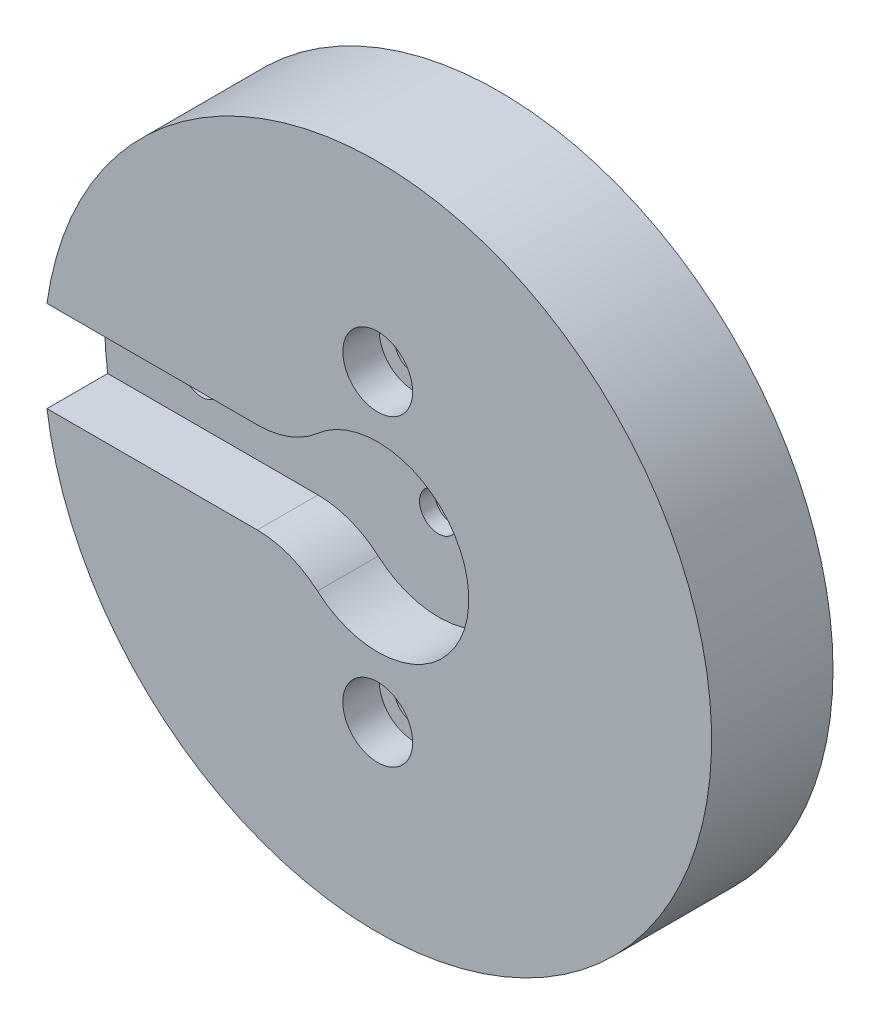
from build123d import *

# Parameters (mm, degrees)
SKETCH3_R                = 7.408333333
BOSS_EXTRUDE1_DEPTH      = 7.62
CUT_EXTRUDE1_START       = -8.62
CUT_EXTRUDE1_DEPTH       = 9.62
FILLET1_R                = 0.355076163
CIRPATTERN1_COUNT        = 12
FILLET1_OF_CIRPATTERN1_R = 0.355076163
SCALE1_SCALE             = 2.5
SKETCH10_R               = 27.94
BOSS_EXTRUDE4_DEPTH      = 10.16
SKETCH11_R               = 5.08
CUT_EXTRUDE5_DEPTH       = 30.21
CUT_EXTRUDE6_DEPTH       = 5.08
SKETCH13_R               = 1.5875
CUT_EXTRUDE12_DEPTH      = 25.1300001
SKETCH16_R               = 2.74955
CUT_EXTRUDE13_DEPTH      = 3.81
SKETCH18_R               = 5.08
BOSS_EXTRUDE5_DEPTH      = 24.13
SKETCH19_R               = 2.794
CUT_EXTRUDE14_DEPTH      = 22.86
SKETCH20_R               = 1.5875
CUT_EXTRUDE15_DEPTH      = 7.62
SKETCH21_R               = 26.202104712
GEAR_CUT_EXTRUDE_DEPTH   = 19.05
SKETCH22_R               = 1.651
CUT_EXTRUDE17_DEPTH      = 10.16
SKETCH23_R               = 2.921
CUT_EXTRUDE18_DEPTH      = 3.048


with BuildPart() as part:
    # Sketch3 → Boss-Extrude1 (new body)
    with BuildSketch(Plane.XY):
        Circle(SKETCH3_R)
    extrude(amount=-BOSS_EXTRUDE1_DEPTH)

    # Sketch4 → Cut-Extrude1 (cut)
    with BuildSketch(Plane.XY.offset(CUT_EXTRUDE1_START)):
        with BuildLine():
            Line((4.993301754, 0.581811335), (5.926950078, 0.690598508))
            add(Edge.make_bspline(
                [(5.926950078, 0.690598508), (5.929318191, 0.690911872), (5.935944647, 0.691904892), (5.948407954, 0.694232443), (5.96863478, 0.69866684), (5.994230847, 0.70524939), (6.027084964, 0.714822349), (6.065467787, 0.727462413), (6.107282331, 0.74277265), (6.152345854, 0.760950457), (6.196898763, 0.780422108), (6.240942495, 0.801081108), (6.284441008, 0.822769247), (6.336662498, 0.8503395), (6.398612769, 0.885198626), (6.469984516, 0.92853373), (6.54965538, 0.980716028), (6.629400976, 1.037091207), (6.706647925, 1.095172788), (6.78320647, 1.156800213), (6.856219389, 1.218511327), (6.930432721, 1.285554849), (6.998115798, 1.348944008), (7.07205666, 1.423150182), (7.131183599, 1.483972917), (7.190627906, 1.549410219), (7.219315962, 1.581641114), (7.233873511, 1.598273068)],
                knots=[0, 0, 0, 0, 0, 0.005376749, 0.015083688, 0.02853182, 0.046610139, 0.064854849, 0.092110525, 0.119476176, 0.146842496, 0.174208854, 0.201574956, 0.228941013, 0.256307345, 0.307035032, 0.361767352, 0.416499661, 0.471231937, 0.525964282, 0.580696615, 0.635428982, 0.690161387, 0.744893688, 0.799626082, 0.854358408, 0.909090915, 0.909090915, 0.909090915, 0.909090915, 0.909090915], degree=4))
            ThreePointArc((7.233873511, 1.598273068), (7.408333333, 0), (7.233873511, -1.598273068))
            add(Edge.make_bspline(
                [(5.926950078, -0.690598508), (5.929318191, -0.690911872), (5.935944647, -0.691904892), (5.948407954, -0.694232443), (5.96863478, -0.69866684), (5.994230847, -0.70524939), (6.027084964, -0.714822349), (6.065467787, -0.727462413), (6.107282331, -0.74277265), (6.152345854, -0.760950457), (6.196898763, -0.780422108), (6.240942495, -0.801081108), (6.284441008, -0.822769247), (6.336662498, -0.8503395), (6.398612769, -0.885198626), (6.469984516, -0.92853373), (6.54965538, -0.980716028), (6.629400976, -1.037091207), (6.706647925, -1.095172788), (6.78320647, -1.156800213), (6.856219389, -1.218511327), (6.930432721, -1.285554849), (6.998115798, -1.348944008), (7.07205666, -1.423150182), (7.131183599, -1.483972917), (7.190627906, -1.549410219), (7.219315962, -1.581641114), (7.233873511, -1.598273068)],
                knots=[0, 0, 0, 0, 0, 0.005376749, 0.015083688, 0.02853182, 0.046610139, 0.064854849, 0.092110525, 0.119476176, 0.146842496, 0.174208854, 0.201574956, 0.228941013, 0.256307345, 0.307035032, 0.361767352, 0.416499661, 0.471231937, 0.525964282, 0.580696615, 0.635428982, 0.690161387, 0.744893688, 0.799626082, 0.854358408, 0.909090915, 0.909090915, 0.909090915, 0.909090915, 0.909090915], degree=4))
            Line((5.926950078, -0.690598508), (4.993301754, -0.581811335))
            ThreePointArc((4.993301754, -0.581811335), (5.027083333, 0), (4.993301754, 0.581811335))
        make_face()
    cut_extrude1 = extrude(amount=CUT_EXTRUDE1_DEPTH, mode=Mode.SUBTRACT)

    # Fillet1
    fillet1_edges = [part.edges().sort_by_distance(p)[0] for p in [
        (4.993301754, -0.581811335, -3.81),
        (4.993301754, 0.581811335, -3.81),
    ]]
    fillet(fillet1_edges, radius=FILLET1_R)

    # CirPattern1: Cut-Extrude1 ×12 about axis
    cirpattern1_axis = Axis((0, 0, 6.35), (0, 0, -1))
    for i in range(1, CIRPATTERN1_COUNT):
        add(cut_extrude1.rotate(cirpattern1_axis, i * 360 / CIRPATTERN1_COUNT), mode=Mode.SUBTRACT)

    # Fillet1 of CirPattern1
    fillet1_of_cirpattern1_edges = [part.edges().sort_by_distance(p)[0] for p in [
        (4.0334205, -3.000514274, -3.81),
        (4.615231836, -1.99278748, -3.81),
        (1.99278748, -4.615231836, -3.81),
        (3.000514274, -4.0334205, -3.81),
        (-0.581811335, -4.993301754, -3.81),
        (0.581811335, -4.993301754, -3.81),
        (-3.000514274, -4.0334205, -3.81),
        (-1.99278748, -4.615231836, -3.81),
        (-4.615231836, -1.99278748, -3.81),
        (-4.0334205, -3.000514274, -3.81),
        (-4.993301754, 0.581811335, -3.81),
        (-4.993301754, -0.581811335, -3.81),
        (-4.0334205, 3.000514274, -3.81),
        (-4.615231836, 1.99278748, -3.81),
        (-1.99278748, 4.615231836, -3.81),
        (-3.000514274, 4.0334205, -3.81),
        (0.581811335, 4.993301754, -3.81),
        (-0.581811335, 4.993301754, -3.81),
        (3.000514274, 4.0334205, -3.81),
        (1.99278748, 4.615231836, -3.81),
        (4.615231836, 1.99278748, -3.81),
        (4.0334205, 3.000514274, -3.81),
    ]]
    fillet(fillet1_of_cirpattern1_edges, radius=FILLET1_OF_CIRPATTERN1_R)


with BuildPart() as part_1:
    # Scale1: scaled about (0, 0, 0)
    add(part.part.scale(SCALE1_SCALE))

    # Sketch10 → Boss-Extrude4 (add)
    with BuildSketch(Plane.XY):
        Circle(SKETCH10_R)
    extrude(amount=BOSS_EXTRUDE4_DEPTH)

    # Sketch11 → Cut-Extrude5 (cut, through all)
    with BuildSketch(Plane(origin=(0, 0, -19.05), x_dir=(-1, 0, 0), z_dir=(0, 0, -1))):
        Circle(SKETCH11_R)
    extrude(amount=-CUT_EXTRUDE5_DEPTH, mode=Mode.SUBTRACT)

    # Sketch12 → Cut-Extrude6 (cut)
    with BuildSketch(Plane.XY.offset(10.16)):
        with BuildLine():
            Line((-10.080312495, -3.81), (-28.438556916, -3.81))
            Line((-28.438556916, -3.81), (-28.438556916, 3.81))
            Line((-28.438556916, 3.81), (-10.080312495, 3.81))
            ThreePointArc((-10.080312495, 3.81), (-7.386235659, 4.302142678), (-5.040156248, 5.715))
            ThreePointArc((-5.040156248, 5.715), (7.62, 0), (-5.040156248, -5.715))
            ThreePointArc((-5.040156248, -5.715), (-7.386235659, -4.302142678), (-10.080312495, -3.81))
        make_face()
    extrude(amount=-CUT_EXTRUDE6_DEPTH, mode=Mode.SUBTRACT)

    # Sketch13 → Cut-Extrude12 (cut, through all)
    with BuildSketch(Plane.XY.offset(5.08)):
        with Locations((-19.812, 0)):
            Circle(SKETCH13_R)
    extrude(amount=-CUT_EXTRUDE12_DEPTH, mode=Mode.SUBTRACT)

    # Sketch16 → Cut-Extrude13 (cut)
    with BuildSketch(Plane(origin=(0, 0, 0), x_dir=(-1, 0, 0), z_dir=(0, 0, -1))):
        with Locations((19.812, 0)):
            Circle(SKETCH16_R)
    extrude(amount=-CUT_EXTRUDE13_DEPTH, mode=Mode.SUBTRACT)

    # Sketch18 → Boss-Extrude5 (add)
    with BuildSketch(Plane(origin=(0, 0, -19.05), x_dir=(-1, 0, 0), z_dir=(0, 0, -1))):
        Circle(SKETCH18_R)
    extrude(amount=-BOSS_EXTRUDE5_DEPTH)

    # Sketch19 → Cut-Extrude14 (cut)
    with BuildSketch(Plane(origin=(0, 0, -19.05), x_dir=(-1, 0, 0), z_dir=(0, 0, -1))):
        Circle(SKETCH19_R)
    extrude(amount=-CUT_EXTRUDE14_DEPTH, mode=Mode.SUBTRACT)

    # Sketch20 → Cut-Extrude15 (cut)
    with BuildSketch(Plane(origin=(0, 0, 3.81), x_dir=(-1, 0, 0), z_dir=(0, 0, -1))):
        Circle(SKETCH20_R)
    extrude(amount=-CUT_EXTRUDE15_DEPTH, mode=Mode.SUBTRACT)

    # Sketch21 → Gear Cut Extrude (cut)
    with BuildSketch(Plane(origin=(0, 0, -19.05), x_dir=(-1, 0, 0), z_dir=(0, 0, -1))):
        Circle(SKETCH21_R)
    extrude(amount=-GEAR_CUT_EXTRUDE_DEPTH, mode=Mode.SUBTRACT)

    # Sketch22 → Cut-Extrude17 (cut)
    with BuildSketch(Plane.XY.offset(10.16)):
        with Locations((0, 12.7)):
            Circle(SKETCH22_R)
        with Locations((0, -12.7)):
            Circle(SKETCH22_R)
    extrude(amount=-CUT_EXTRUDE17_DEPTH, mode=Mode.SUBTRACT)

    # Sketch23 → Cut-Extrude18 (cut)
    with BuildSketch(Plane.XY.offset(10.16)):
        with Locations((0, -12.7)):
            Circle(SKETCH23_R)
        with Locations((0, 12.7)):
            Circle(SKETCH23_R)
    extrude(amount=-CUT_EXTRUDE18_DEPTH, mode=Mode.SUBTRACT)


solid = part_1.part
